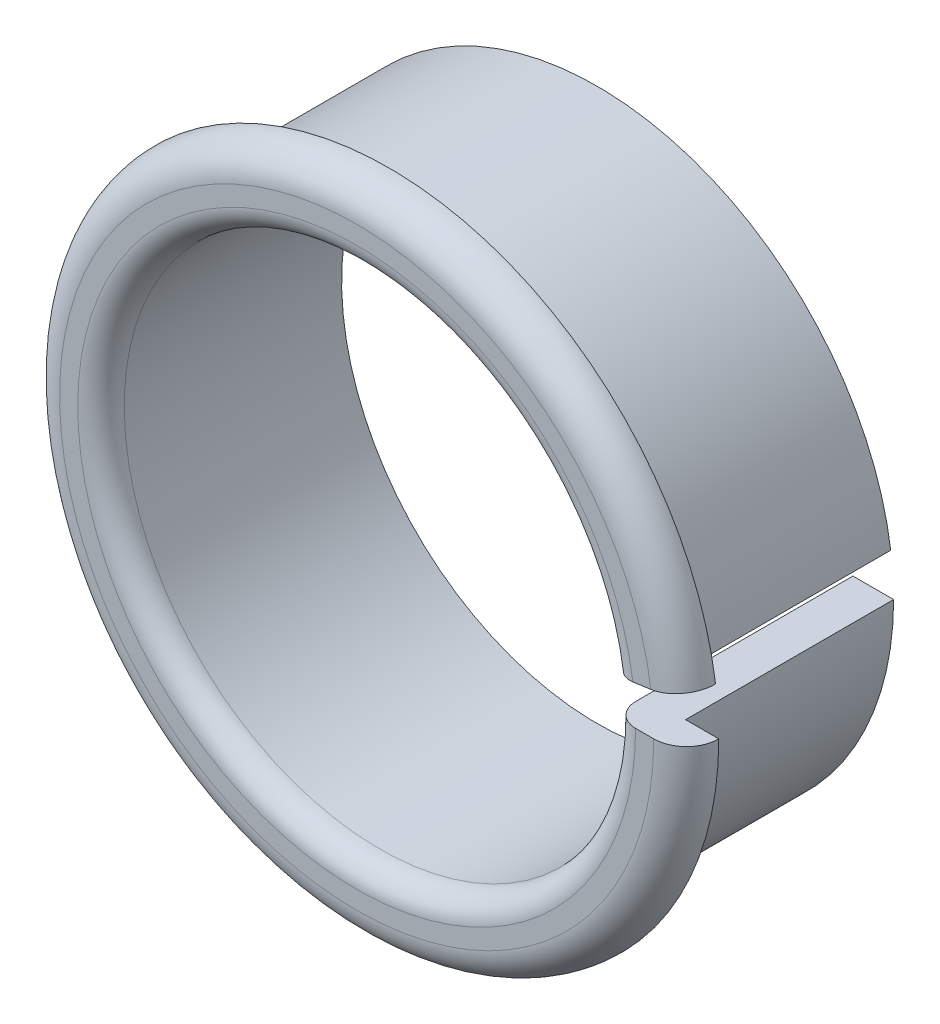
from build123d import *

# Parameters (mm, degrees)
REVOLVE1_ANGLE = 352


with BuildPart() as part:
    # Sketch1 → Revolve1 (revolve)
    with BuildSketch(Plane(origin=(0, 0, 0), x_dir=(1, 0, 0), z_dir=(0, 1, 0))):
        with BuildLine():
            Line((11, 10.35), (11, 1))
            ThreePointArc((11, 1), (11.292893219, 0.292893219), (12, 0))
            Line((12, 0), (12.782227205, 0))
            ThreePointArc((12.782227205, 0), (13.770601827, 0.409398173), (14.18, 1.397772795))
            Line((14.18, 1.397772795), (12.75, 1.397772795))
            Line((12.75, 1.397772795), (12.75, 10.35))
            Line((12.75, 10.35), (11, 10.35))
        make_face()
    revolve(axis=Axis((0, 0, 0), (0, 0, -1)), revolution_arc=REVOLVE1_ANGLE)


solid = part.part
